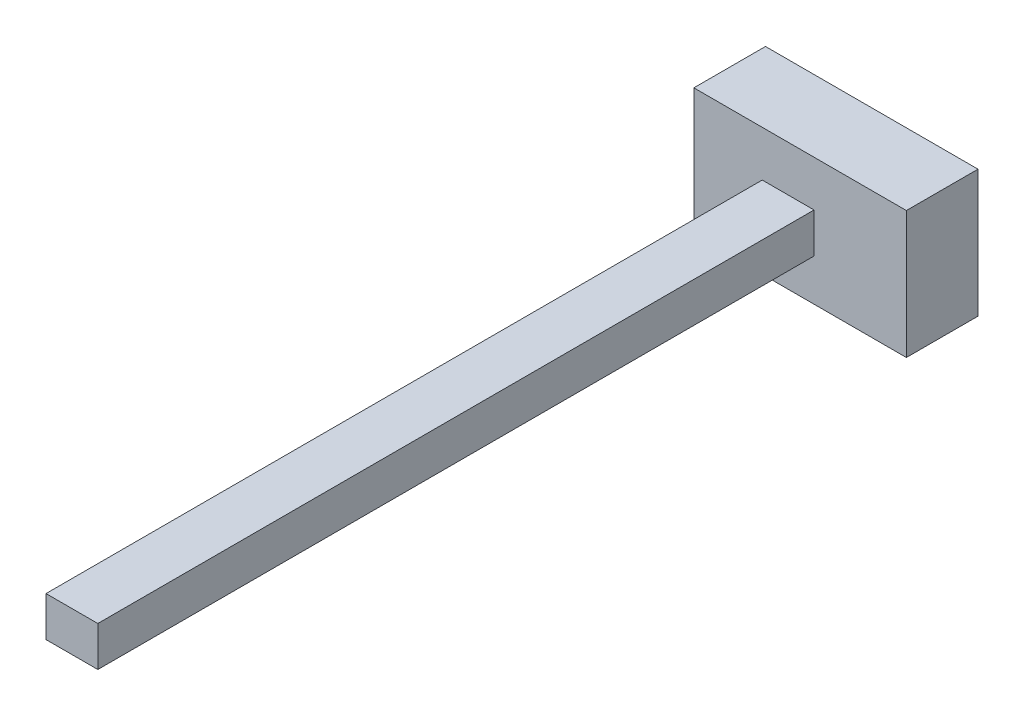
from build123d import *

# Parameters (mm, degrees)
SKETCH_1_W      = 29.670919937
SKETCH_1_H      = 17.775845147
EXTRUDE_1_DEPTH = 10
SKETCH_2_W      = 7.236184278
SKETCH_2_H      = 5.568058893
EXTRUDE_3_DEPTH = 100


with BuildPart() as part:
    # 草圖1 → 填料-伸長1 (new body)
    with BuildSketch(Plane.XY):
        with Locations((14.835459969, 8.887922574)):
            Rectangle(SKETCH_1_W, SKETCH_1_H)
    extrude(amount=EXTRUDE_1_DEPTH)

    # 草圖2 → 填料-伸長3 (add)
    with BuildSketch(Plane.XY.offset(10)):
        with Locations((13.165038439, 8.615088056)):
            Rectangle(SKETCH_2_W, SKETCH_2_H)
    extrude(amount=EXTRUDE_3_DEPTH)


solid = part.part
